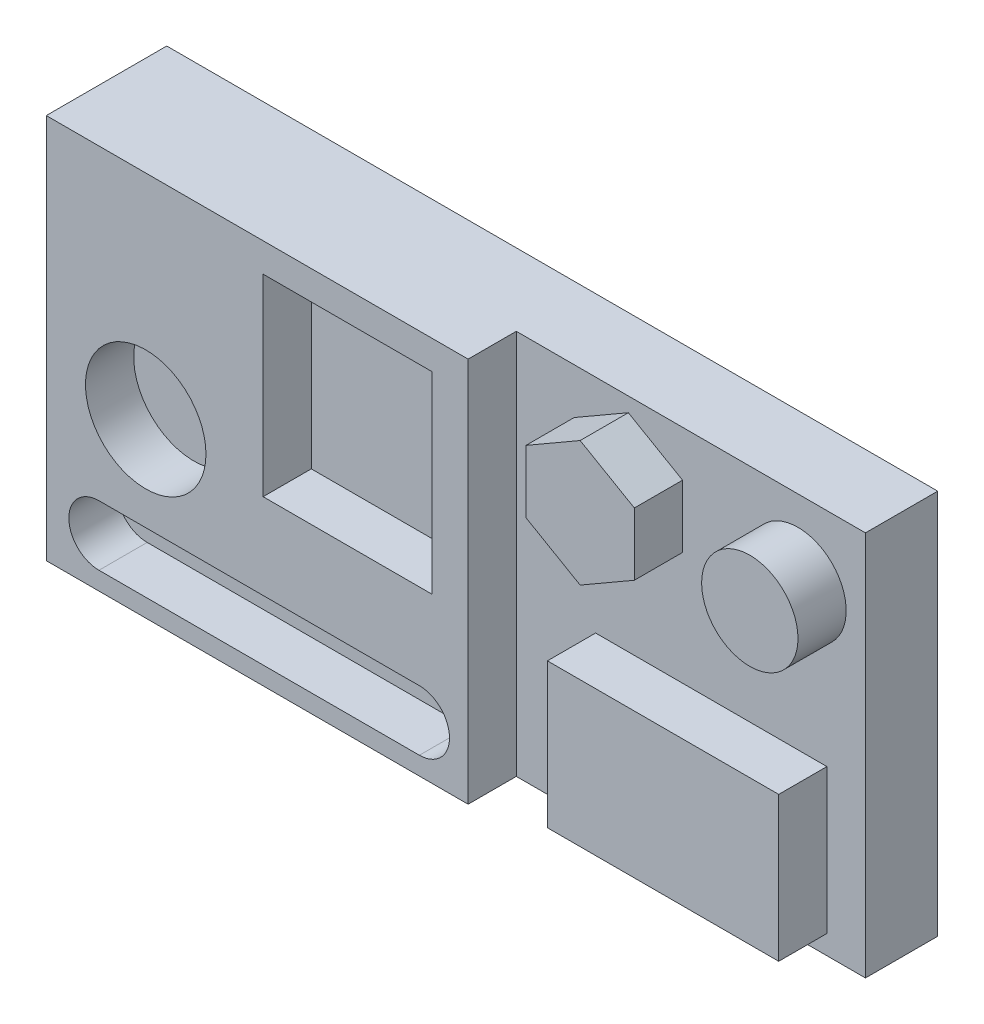
from build123d import *

# Parameters (mm, degrees)
SKETCH2_W           = 203.2
SKETCH2_H           = 101.6
BOSS_EXTRUDE1_DEPTH = 31.75
SKETCH3_W           = 92.020686849
SKETCH3_H           = 101.6
CUT_EXTRUDE1_DEPTH  = 12.7
SKETCH4_R           = 12.7
SKETCH4_W           = 60.96
SKETCH4_H           = 38.1
BOSS_EXTRUDE2_DEPTH = 12.7
SKETCH6_R           = 15.875
SKETCH6_W           = 44.45
SKETCH6_H           = 50.8
CUT_EXTRUDE2_DEPTH  = 12.7
BOSS_EXTRUDE3_DEPTH = 12.7


with BuildPart() as part:
    # Sketch2 → Boss-Extrude1 (new body)
    with BuildSketch(Plane.XY):
        Rectangle(SKETCH2_W, SKETCH2_H)
    extrude(amount=BOSS_EXTRUDE1_DEPTH)

    # Sketch3 → Cut-Extrude1 (cut)
    with BuildSketch(Plane.XY.offset(31.75)):
        with Locations((55.589656576, 0)):
            Rectangle(SKETCH3_W, SKETCH3_H)
    extrude(amount=-CUT_EXTRUDE1_DEPTH, mode=Mode.SUBTRACT)

    # Sketch4 → Boss-Extrude2 (add)
    with BuildSketch(Plane.XY.offset(19.05)):
        with Locations(Location((83.82, 30.48, 0), (0, 0, 180))):  # turned: the seam where the file's is
            Circle(SKETCH4_R)
        with Locations((60.96, -26.67)):
            Rectangle(SKETCH4_W, SKETCH4_H)
    extrude(amount=BOSS_EXTRUDE2_DEPTH)

    # Sketch6 → Cut-Extrude2 (cut)
    with BuildSketch(Plane.XY.offset(31.75)):
        with Locations((-75.387587267, -5.436604851)):
            Circle(SKETCH6_R)
        with BuildLine():
            Line((-87.710558262, -30.1625), (-3.261962911, -30.1625))
            ThreePointArc((-3.261962911, -30.1625), (4.675537089, -38.1), (-3.261962911, -46.0375))
            Line((-3.261962911, -46.0375), (-87.710558262, -46.0375))
            ThreePointArc((-87.710558262, -46.0375), (-95.648058262, -38.1), (-87.710558262, -30.1625))
        make_face()
        with Locations((-22.225, 17.78)):
            Rectangle(SKETCH6_W, SKETCH6_H)
    extrude(amount=-CUT_EXTRUDE2_DEPTH, mode=Mode.SUBTRACT)

    # Sketch7 → Boss-Extrude3 (add)
    with BuildSketch(Plane.XY.offset(19.05)):
        Polygon((39.106813151, 46.977783942), (24.819313151, 38.728891971), (24.819313151, 22.231108029), (39.106813151, 13.982216058), (53.394313151, 22.231108029), (53.394313151, 38.728891971), align=None)
    extrude(amount=BOSS_EXTRUDE3_DEPTH)


solid = part.part
